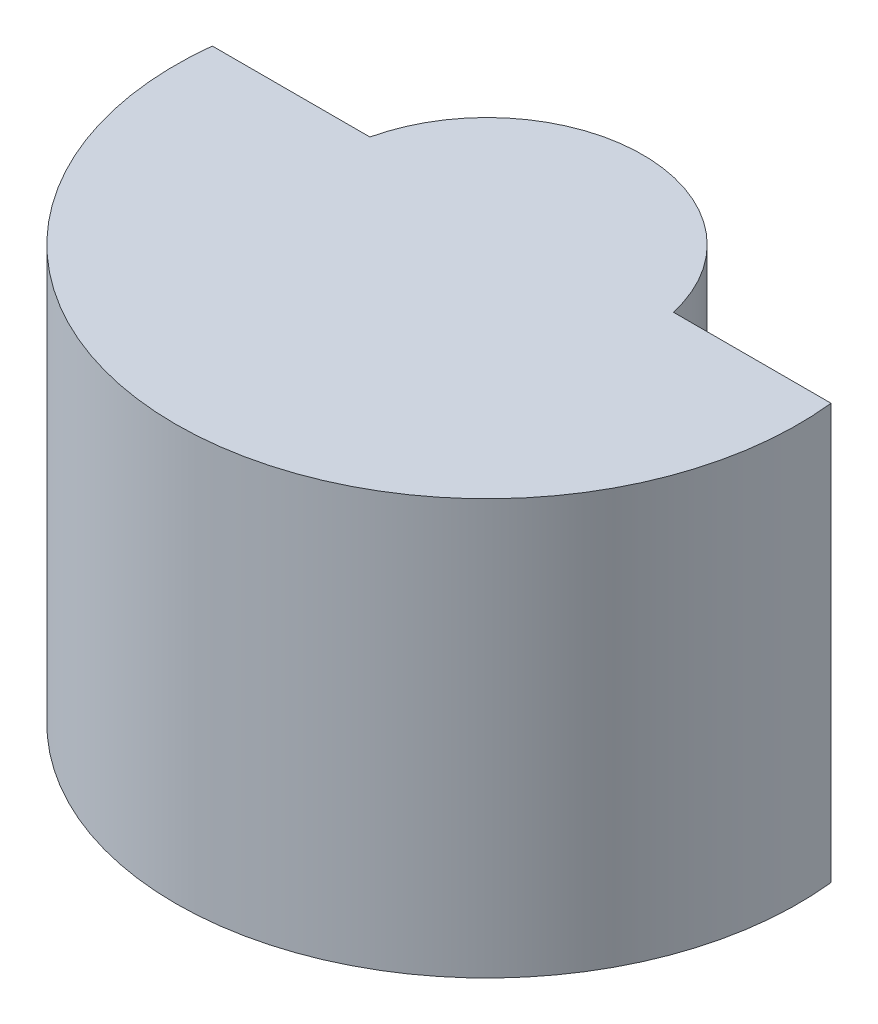
from build123d import *

# Parameters (mm, degrees)
AUFSATZ_LINEAR_START            = 0.5
AUFSATZ_LINEAR_AUSTRAGEN1_DEPTH = 6


with BuildPart() as part:
    # Skizze2 → Aufsatz-Linear austragen1 (new body)
    with BuildSketch(Plane(origin=(0, 75.95, 0), x_dir=(1, 0, 0), z_dir=(0, 1, 0)).offset(AUFSATZ_LINEAR_START)):
        with BuildLine():
            Line((-4.472135955, 0), (-2.193741097, 0))
            ThreePointArc((-2.193741097, 0), (0, 1.75), (2.193741097, 0))
            Line((2.193741097, 0), (4.472135955, 0))
            ThreePointArc((4.472135955, 0), (0, -5), (-4.472135955, 0))
        make_face()
    extrude(amount=AUFSATZ_LINEAR_AUSTRAGEN1_DEPTH)

    # Skizze6 → Schnitt-Rotation4 (revolve, cut)
    with BuildSketch(Plane(origin=(0, 79.45, 0), x_dir=(-1, 0, 0), z_dir=(0, -1, 0))):
        Polygon((-1.7, 0.973940297), (-1.7, -3.026059703), (0, -3.026059703), (0, 1.75), (0, 1.9), (-1.7, 1.9), align=None)
    revolve(axis=Axis((0, 79.45, -1.75), (0, 0, 1)), mode=Mode.SUBTRACT)


solid = part.part
